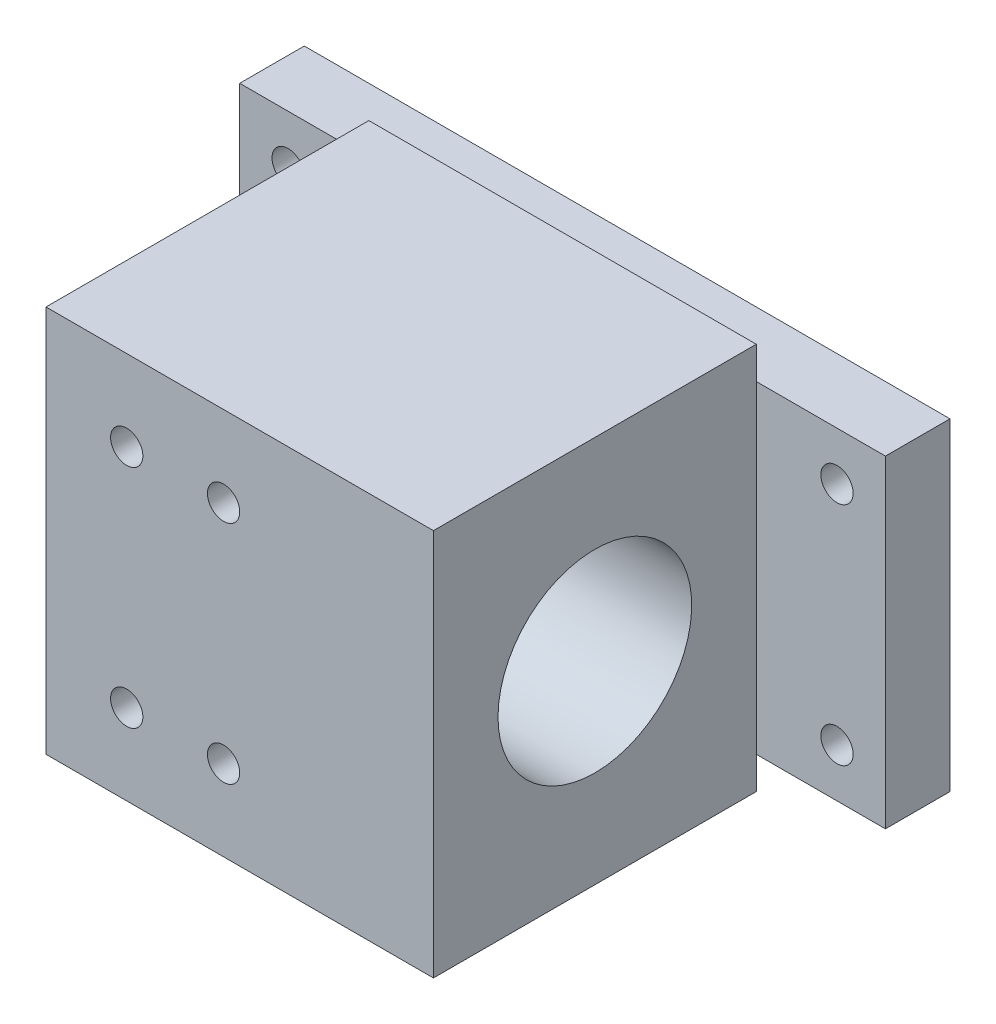
from build123d import *

# Parameters (mm, degrees)
SKETCH1_W           = 100
SKETCH1_H           = 50
SKETCH1_R           = 2.5
BOSS_EXTRUDE1_DEPTH = 10
SKETCH2_W           = 60
SKETCH2_H           = 60
BOSS_EXTRUDE2_DEPTH = 50
SKETCH3_R           = 15
CUT_EXTRUDE1_DEPTH  = 101
SKETCH5_R           = 2.5
CUT_EXTRUDE3_DEPTH  = 10


with BuildPart() as part:
    # Sketch1 → Boss-Extrude1 (new body)
    with BuildSketch(Plane.XY):
        Rectangle(SKETCH1_W, SKETCH1_H)
        with Locations((-42.5, 17.5)):
            Circle(SKETCH1_R, mode=Mode.SUBTRACT)
        with Locations((42.5, 17.5)):
            Circle(SKETCH1_R, mode=Mode.SUBTRACT)
        with Locations((42.5, -17.5)):
            Circle(SKETCH1_R, mode=Mode.SUBTRACT)
        with Locations((-42.5, -17.5)):
            Circle(SKETCH1_R, mode=Mode.SUBTRACT)
    extrude(amount=BOSS_EXTRUDE1_DEPTH)

    # Sketch2 → Boss-Extrude2 (add)
    with BuildSketch(Plane.XY.offset(10)):
        Rectangle(SKETCH2_W, SKETCH2_H)
    extrude(amount=BOSS_EXTRUDE2_DEPTH)

    # Sketch3 → Cut-Extrude1 (cut)
    with BuildSketch(Plane.ZY.offset(30)):
        with Locations((35, 0)):
            Circle(SKETCH3_R)
    extrude(amount=-CUT_EXTRUDE1_DEPTH, mode=Mode.SUBTRACT)

    # Sketch5 → Cut-Extrude3 (cut)
    with BuildSketch(Plane.XY.offset(60)):
        with Locations((-17.5, 17.5)):
            Circle(SKETCH5_R)
        with Locations((-2.5, 17.5)):
            Circle(SKETCH5_R)
        with Locations((-2.5, -17.5)):
            Circle(SKETCH5_R)
        with Locations((-17.5, -17.5)):
            Circle(SKETCH5_R)
    extrude(amount=-CUT_EXTRUDE3_DEPTH, mode=Mode.SUBTRACT)


solid = part.part
